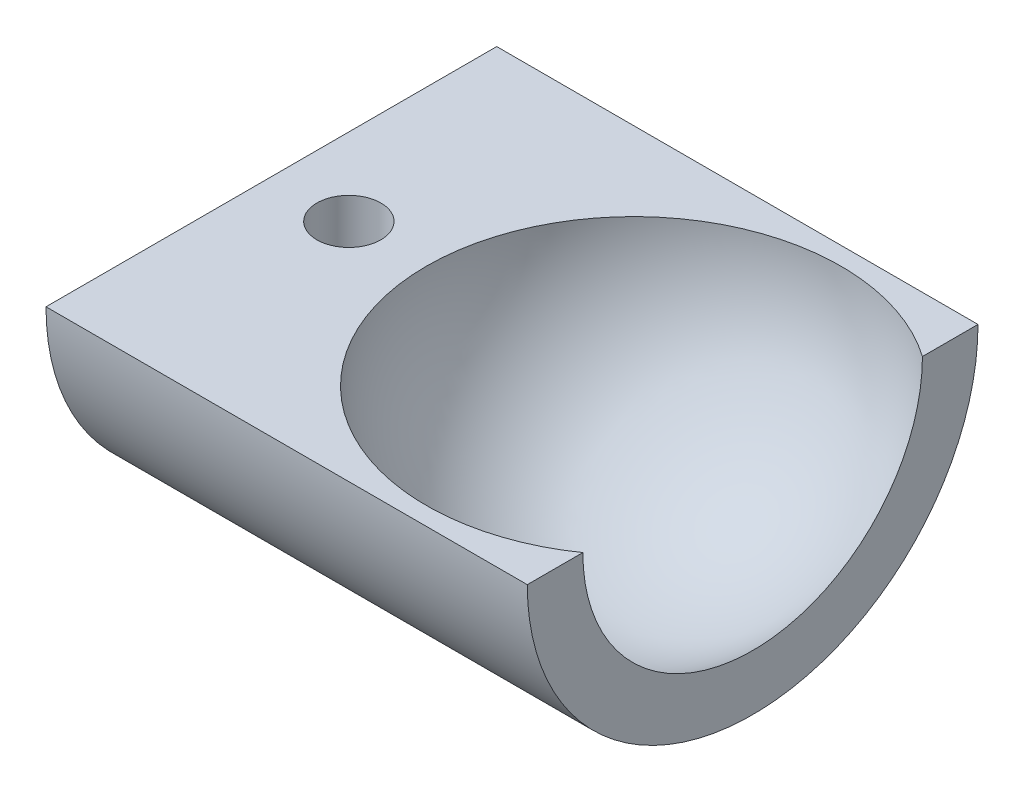
from build123d import *

# Parameters (mm, degrees)
CORTAR_EXTRUIR5_DEPTH = 50
CROQUIS8_R            = 1.65
CORTAR_EXTRUIR6_DEPTH = 50


with BuildPart() as part:
    # Croquis1 → Revolución4 (revolve)
    with BuildSketch(Plane(origin=(0, 0, 0), x_dir=(1, 0, 0), z_dir=(0, 1, 0))):
        with BuildLine():
            Line((-10.7, 0), (-18.7, 0))
            Line((-18.7, 0), (-18.7, 11.630777084))
            Line((-18.7, 11.630777084), (6.139681858, 11.630777084))
            Line((6.139681858, 11.630777084), (6.139681858, 8.763236085))
            ThreePointArc((6.139681858, 8.763236085), (-4.939403006, 9.491696263), (-10.7, 0))
        make_face()
    revolve(axis=Axis((-10.7, 0, 0), (-1, 0, 0)))

    # Croquis7 → Cortar-Extruir5 (cut)
    with BuildSketch(Plane(origin=(6.139681858, 0, 0), x_dir=(0, 0, -1), z_dir=(1, 0, 0))):
        Polygon((0, 0), (14.104035702, 0), (14.104035702, 12.472423118), (-13.194097915, 12.472423118), (-13.194097915, 0), align=None)
    extrude(amount=-CORTAR_EXTRUIR5_DEPTH, mode=Mode.SUBTRACT)

    # Croquis8 → Cortar-Extruir6 (cut)
    with BuildSketch(Plane(origin=(0, 0, 0), x_dir=(1, 0, 0), z_dir=(0, 1, 0))):
        with Locations((-14.7, 0)):
            Circle(CROQUIS8_R)
    extrude(amount=-CORTAR_EXTRUIR6_DEPTH, mode=Mode.SUBTRACT)


solid = part.part
